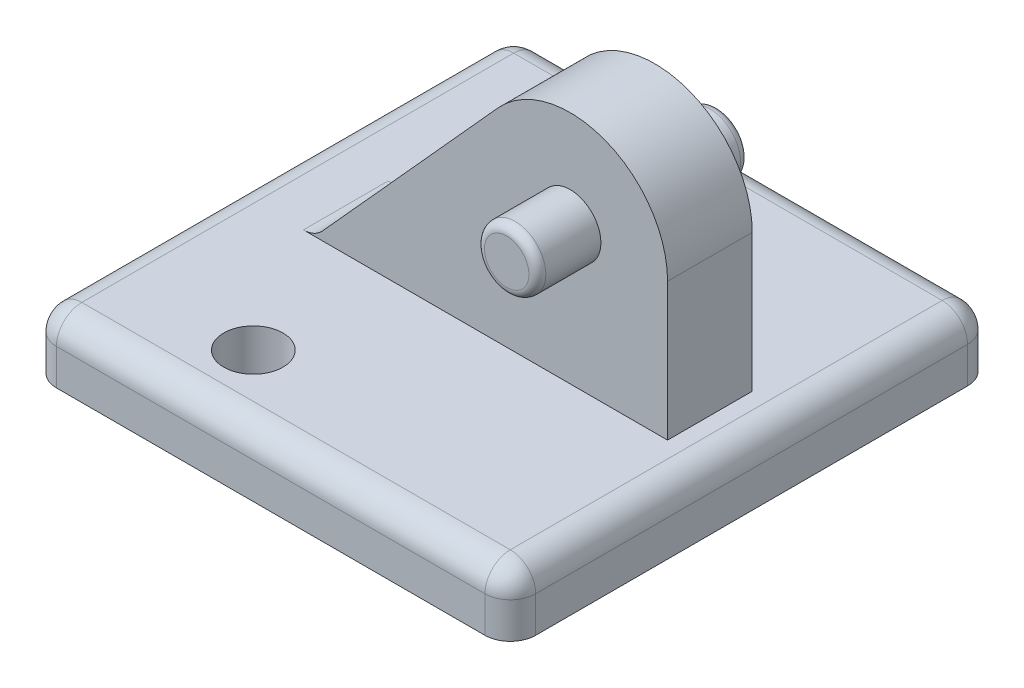
from build123d import *

# Parameters (mm, degrees)
SKETCH1_W           = 14.3764
SKETCH1_H           = 14.478
SKETCH1_R           = 0.889
BOSS_EXTRUDE1_DEPTH = 1.8415
SKETCH2_R           = 0.92075
BOSS_EXTRUDE2_DEPTH = 1.27
SKETCH2_4_R         = 0.92075
BOSS_EXTRUDE3_DEPTH = 3.175
FILLET1_R           = 0.762
FILLET2_R           = 0.254


with BuildPart() as part:
    # Sketch1 → Boss-Extrude1 (new body)
    with BuildSketch(Plane(origin=(0, 0, 0), x_dir=(1, 0, 0), z_dir=(0, 1, 0))):
        Rectangle(SKETCH1_W, SKETCH1_H)
        with Locations((-2.6162, 5.1435)):
            Circle(SKETCH1_R, mode=Mode.SUBTRACT)
        with Locations((-2.6162, -5.1435)):
            Circle(SKETCH1_R, mode=Mode.SUBTRACT)
    extrude(amount=BOSS_EXTRUDE1_DEPTH)

    # Sketch2 → Boss-Extrude2 (add, symmetric)
    with BuildSketch(Plane.XY):
        with BuildLine():
            Line((0.848172569, 7.926885609), (-4.6482, 1.8415))
            Line((-4.6482, 1.8415), (5.93687295, 1.8415))
            Line((5.93687295, 1.8415), (5.93687295, 5.969))
            ThreePointArc((5.93687295, 5.969), (4.064774324, 8.695178077), (0.848172569, 7.926885609))
        make_face()
        with Locations((3.01587295, 5.969)):
            Circle(SKETCH2_R, mode=Mode.SUBTRACT)
    extrude(amount=BOSS_EXTRUDE2_DEPTH, both=True)

    # Sketch2_4 → Boss-Extrude3 (add, symmetric)
    with BuildSketch(Plane.XY):
        with Locations((3.01587295, 5.969)):
            Circle(SKETCH2_4_R)
    extrude(amount=BOSS_EXTRUDE3_DEPTH, both=True)

    # Fillet1
    fillet1_edges = [part.edges().sort_by_distance(p)[0] for p in [
        (7.1882, 0.92075, -7.239),
        (-7.1882, 0.92075, -7.239),
        (7.1882, 0.92075, 7.239),
        (-7.1882, 0.92075, 7.239),
        (7.1882, 1.8415, 0),
        (0, 1.8415, -7.239),
        (0, 1.8415, 7.239),
        (-7.1882, 1.8415, 0),
        (-4.6482, 1.8415, 0),
    ]]
    fillet(fillet1_edges, radius=FILLET1_R)

    # Fillet2
    fillet2_edges = [part.edges().sort_by_distance(p)[0] for p in [
        (2.09512295, 5.969, -3.175),
        (2.09512295, 5.969, 3.175),
    ]]
    fillet(fillet2_edges, radius=FILLET2_R)


solid = part.part
